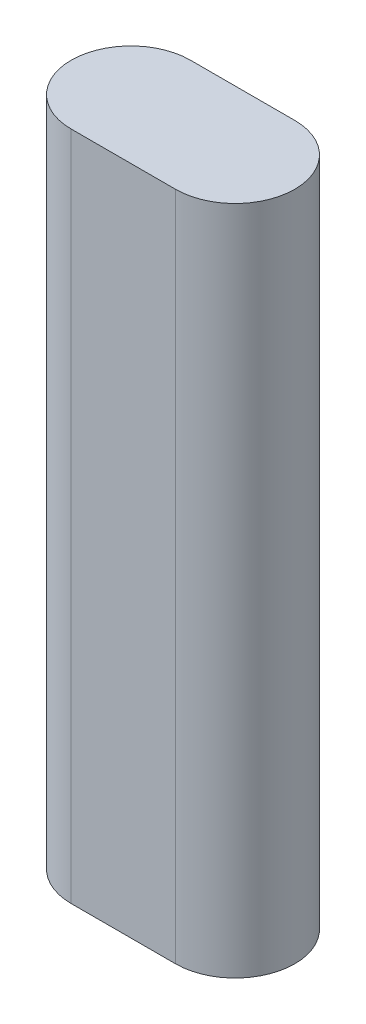
from build123d import *

# Parameters (mm, degrees)
BOSS_EXTRUDE1_DEPTH = 135


with BuildPart() as part:
    # Sketch1 → Boss-Extrude1 (new body)
    with BuildSketch(Plane(origin=(0, 0, 0), x_dir=(1, 0, 0), z_dir=(0, 1, 0))):
        with BuildLine():
            Line((-10.5, 12), (10.5, 12))
            ThreePointArc((10.5, 12), (22.5, 0), (10.5, -12))
            Line((10.5, -12), (-10.5, -12))
            ThreePointArc((-10.5, -12), (-22.5, 0), (-10.5, 12))
        make_face()
    extrude(amount=BOSS_EXTRUDE1_DEPTH)


solid = part.part
